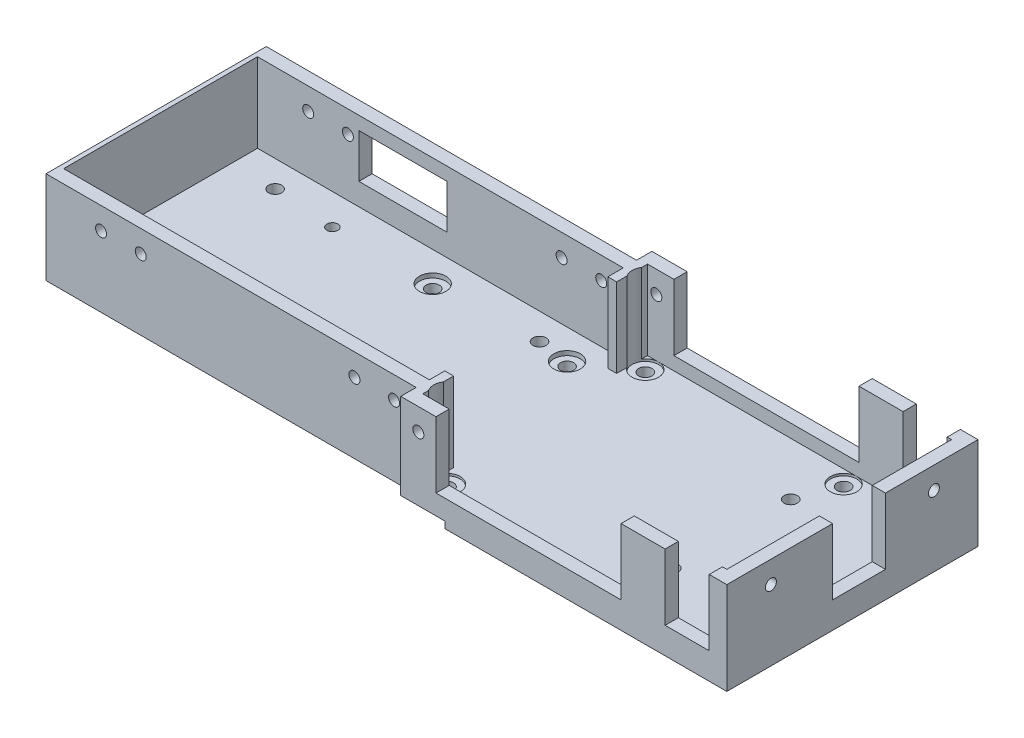
from build123d import *

# Parameters (mm, degrees)
SKETCH1_W               = 158
SKETCH1_H               = 50
BOSS_EXTRUDE1_DEPTH     = 3
SKETCH2_R               = 1.5
SKETCH2_R_2             = 1.25
CUT_EXTRUDE1_DEPTH      = 4
SKETCH4_W               = 74
SKETCH4_H               = 3.5
BOSS_EXTRUDE2_DEPTH     = 3
SKETCH5_R               = 1.5
CUT_EXTRUDE3_DEPTH      = 4
SKETCH6_W               = 84
SKETCH6_H               = 3
SKETCH6_W_2             = 8
SKETCH6_W_3             = 2
SKETCH6_H_2             = 7
SKETCH6_W_4             = 4
SKETCH6_W_5             = 3
SKETCH6_H_3             = 21
SKETCH6_H_4             = 18
SKETCH6_W_6             = 10
BOSS_EXTRUDE3_DEPTH     = 18
SKETCH8_W               = 10
SKETCH8_H               = 3
SKETCH8_H_2             = 2
SKETCH8_W_2             = 42
SKETCH8_W_3             = 3
SKETCH8_H_3             = 12
BOSS_EXTRUDE4_DEPTH     = 3
CUT_EXTRUDE4_REACH      = 55.5
SKETCH9_W               = 20
SKETCH9_H               = 10
CUT_EXTRUDE5_REACH      = 160
SKETCH10_R              = 1.25
SKETCH11_R              = 1.25
CUT_EXTRUDE6_DEPTH      = 54.5
SKETCH12_R              = 1.25
CUT_EXTRUDE7_DEPTH      = 58
SKETCH13_W              = 10
SKETCH13_H              = 1.5
CUT_EXTRUDE8_DEPTH      = 1.5
SKETCH14_R              = 3
CUT_EXTRUDE9_DEPTH      = 19
CUT_EXTRUDE9_DEPTH_BACK = 0.5
SKETCH15_R              = 3
CUT_EXTRUDE10_DEPTH     = 1
SKETCH17_W              = 1
SKETCH17_H              = 44
BOSS_EXTRUDE5_DEPTH     = 18


with BuildPart() as part:
    # Sketch1 → Boss-Extrude1 (new body)
    with BuildSketch(Plane(origin=(0, 0, 0), x_dir=(1, 0, 0), z_dir=(0, 1, 0))):
        with Locations((-43.62052506, -3.090692124)):
            Rectangle(SKETCH1_W, SKETCH1_H)
    extrude(amount=BOSS_EXTRUDE1_DEPTH)

    # Sketch2 → Cut-Extrude1 (cut, through all)
    with BuildSketch(Plane(origin=(0, 3, 0), x_dir=(1, 0, 0), z_dir=(0, 1, 0))):
        with Locations((-75.12052506, 12.159307876)):
            Circle(SKETCH2_R)
        with Locations((-75.12052506, -18.340692124)):
            Circle(SKETCH2_R)
        with Locations((-44.62052506, -18.340692124)):
            Circle(SKETCH2_R)
        with Locations((-44.62052506, 12.159307876)):
            Circle(SKETCH2_R)
        with Locations((7.87947494, -16.590692124)):
            Circle(SKETCH2_R)
        with Locations((7.87947494, 10.409307876)):
            Circle(SKETCH2_R)
        with Locations((-111.62052506, -19.090692124)):
            Circle(SKETCH2_R)
        with Locations((-111.62052506, 12.909307876)):
            Circle(SKETCH2_R)
        with Locations((-97.62052506, 11.909307876)):
            Circle(SKETCH2_R_2)
        with Locations((-97.62052506, -18.090692124)):
            Circle(SKETCH2_R_2)
        with Locations((-51.62052506, 12.909307876)):
            Circle(SKETCH2_R)
        with Locations((-51.62052506, -19.090692124)):
            Circle(SKETCH2_R)
    extrude(amount=-CUT_EXTRUDE1_DEPTH, mode=Mode.SUBTRACT)

    # Sketch4 → Boss-Extrude2 (add)
    with BuildSketch(Plane(origin=(0, 3, 0), x_dir=(1, 0, 0), z_dir=(0, 1, 0))):
        with Locations((-1.62052506, -29.840692124)):
            Rectangle(SKETCH4_W, SKETCH4_H)
        with Locations((-1.62052506, 23.659307876)):
            Rectangle(SKETCH4_W, SKETCH4_H)
    extrude(amount=-BOSS_EXTRUDE2_DEPTH)

    # Sketch5 → Cut-Extrude3 (cut, through all)
    with BuildSketch(Plane(origin=(0, 3, 0), x_dir=(1, 0, 0), z_dir=(0, 1, 0))):
        with Locations((-34.12052506, 19.409307876)):
            Circle(SKETCH5_R)
        with Locations((-34.12052506, -25.590692124)):
            Circle(SKETCH5_R)
        with Locations((10.87947494, 19.409307876)):
            Circle(SKETCH5_R)
        with Locations((10.87947494, -25.590692124)):
            Circle(SKETCH5_R)
    extrude(amount=-CUT_EXTRUDE3_DEPTH, mode=Mode.SUBTRACT)

    # Sketch6 → Boss-Extrude3 (add)
    with BuildSketch(Plane(origin=(0, 3, 0), x_dir=(1, 0, 0), z_dir=(0, 1, 0))):
        Polygon((35.37947494, 25.409307876), (31.37947494, 25.409307876), (31.37947494, 22.409307876), (32.37947494, 22.409307876), (35.37947494, 22.409307876), align=None)
        with Locations((-80.62052506, -26.590692124)):
            Rectangle(SKETCH6_W, SKETCH6_H)
        with Locations((-80.62052506, 20.409307876)):
            Rectangle(SKETCH6_W, SKETCH6_H)
        with Locations((-34.62052506, 23.909307876)):
            Rectangle(SKETCH6_W_2, SKETCH6_H)
        with Locations((-34.62052506, -30.090692124)):
            Rectangle(SKETCH6_W_2, SKETCH6_H)
        with Locations((-37.62052506, -25.090692124)):
            Rectangle(SKETCH6_W_3, SKETCH6_H_2)
        with Locations((-37.62052506, 18.909307876)):
            Rectangle(SKETCH6_W_3, SKETCH6_H_2)
        with Locations((33.37947494, -30.090692124)):
            Rectangle(SKETCH6_W_4, SKETCH6_H)
        with Locations((33.87947494, -18.090692124)):
            Rectangle(SKETCH6_W_5, SKETCH6_H_3)
        with Locations((33.87947494, 13.409307876)):
            Rectangle(SKETCH6_W_5, SKETCH6_H_4)
        with Locations((16.37947494, -30.090692124)):
            Rectangle(SKETCH6_W_6, SKETCH6_H)
        with Locations((16.37947494, 23.909307876)):
            Rectangle(SKETCH6_W_6, SKETCH6_H)
    extrude(amount=BOSS_EXTRUDE3_DEPTH)

    # Sketch8 → Boss-Extrude4 (add)
    with BuildSketch(Plane(origin=(0, 3, 0), x_dir=(1, 0, 0), z_dir=(0, 1, 0))):
        with Locations((26.37947494, -30.090692124)):
            Rectangle(SKETCH8_W, SKETCH8_H)
        with Locations((26.37947494, 24.409307876)):
            Rectangle(SKETCH8_W, SKETCH8_H_2)
        with Locations((-9.62052506, 23.909307876)):
            Rectangle(SKETCH8_W_2, SKETCH8_H)
        with Locations((-9.62052506, -30.090692124)):
            Rectangle(SKETCH8_W_2, SKETCH8_H)
        with Locations((33.87947494, -1.590692124)):
            Rectangle(SKETCH8_W_3, SKETCH8_H_3)
    extrude(amount=BOSS_EXTRUDE4_DEPTH)

    # Sketch9 → Cut-Extrude4 (cut, up to next)
    with BuildSketch(Plane(origin=(0, 0, -21.909307876), x_dir=(-1, 0, 0), z_dir=(0, 0, -1)), mode=Mode.PRIVATE) as cut_extrude4_sk1:
        with Locations((88.62052506, 13)):
            Rectangle(SKETCH9_W, SKETCH9_H)
    cut_extrude4_tool1 = extrude(cut_extrude4_sk1.sketch, amount=-CUT_EXTRUDE4_REACH, mode=Mode.PRIVATE) & part.part
    add(cut_extrude4_tool1.solids().sort_by_distance((-88.620525, 13, -21.909308))[0], mode=Mode.SUBTRACT)

    # Sketch10 → Cut-Extrude5 (cut, up to next)
    with BuildSketch(Plane(origin=(35.37947494, 0, 0), x_dir=(0, 0, -1), z_dir=(1, 0, 0)), mode=Mode.PRIVATE) as cut_extrude5_sk1:
        with Locations((-21.590692124, 16)):
            Circle(SKETCH10_R)
    cut_extrude5_tool1 = extrude(cut_extrude5_sk1.sketch, amount=-CUT_EXTRUDE5_REACH, mode=Mode.PRIVATE) & part.part
    add(cut_extrude5_tool1.solids().sort_by_distance((35.379475, 16, 21.590692))[0], mode=Mode.SUBTRACT)
    # Sketch10 → Cut-Extrude5 (cut, up to next)
    with BuildSketch(Plane(origin=(35.37947494, 0, 0), x_dir=(0, 0, -1), z_dir=(1, 0, 0)), mode=Mode.PRIVATE) as cut_extrude5_sk2:
        with Locations((15.409307876, 16)):
            Circle(SKETCH10_R)
    cut_extrude5_tool2 = extrude(cut_extrude5_sk2.sketch, amount=-CUT_EXTRUDE5_REACH, mode=Mode.PRIVATE) & part.part
    add(cut_extrude5_tool2.solids().sort_by_distance((35.379475, 16, -15.409308))[0], mode=Mode.SUBTRACT)

    # Sketch11 → Cut-Extrude6 (cut, through all)
    with BuildSketch(Plane(origin=(0, 0, -21.909307876), x_dir=(-1, 0, 0), z_dir=(0, 0, -1))):
        with Locations((43.62052506, 16)):
            Circle(SKETCH11_R)
        with Locations((110.12052506, 16)):
            Circle(SKETCH11_R)
        with Locations((52.62052506, 16)):
            Circle(SKETCH11_R)
        with Locations((101.12052506, 16)):
            Circle(SKETCH11_R)
    extrude(amount=-CUT_EXTRUDE6_DEPTH, mode=Mode.SUBTRACT)

    # Sketch12 → Cut-Extrude7 (cut, through all)
    with BuildSketch(Plane(origin=(0, 0, -25.409307876), x_dir=(-1, 0, 0), z_dir=(0, 0, -1))):
        with Locations((34.62052506, 16)):
            Circle(SKETCH12_R)
    extrude(amount=-CUT_EXTRUDE7_DEPTH, mode=Mode.SUBTRACT)

    # Sketch13 → Cut-Extrude8 (cut)
    with BuildSketch(Plane(origin=(0, 0, 0), x_dir=(-1, 0, 0), z_dir=(0, -1, 0))):
        with Locations((33.62052506, -30.840692124)):
            Rectangle(SKETCH13_W, SKETCH13_H)
        with Locations((33.62052506, 24.659307876)):
            Rectangle(SKETCH13_W, SKETCH13_H)
    extrude(amount=-CUT_EXTRUDE8_DEPTH, mode=Mode.SUBTRACT)

    # Sketch14 → Cut-Extrude9 (cut, two sides)
    with BuildSketch(Plane(origin=(0, 3, 0), x_dir=(1, 0, 0), z_dir=(0, 1, 0))) as cut_extrude9_sk:
        with Locations((10.87947494, -25.590692124)):
            Circle(SKETCH14_R)
        with Locations((-34.12052506, -25.590692124)):
            Circle(SKETCH14_R)
        with Locations((-34.12052506, 19.409307876)):
            Circle(SKETCH14_R)
        with Locations((10.87947494, 19.409307876)):
            Circle(SKETCH14_R)
    extrude(amount=CUT_EXTRUDE9_DEPTH, mode=Mode.SUBTRACT)
    extrude(cut_extrude9_sk.sketch, amount=-CUT_EXTRUDE9_DEPTH_BACK, mode=Mode.SUBTRACT)

    # Sketch15 → Cut-Extrude10 (cut)
    with BuildSketch(Plane(origin=(0, 3, 0), x_dir=(1, 0, 0), z_dir=(0, 1, 0))):
        with Locations((-75.12052506, 12.159307876)):
            Circle(SKETCH15_R)
        with Locations((-75.12052506, -18.340692124)):
            Circle(SKETCH15_R)
        with Locations((-44.62052506, 12.159307876)):
            Circle(SKETCH15_R)
        with Locations((-44.62052506, -18.340692124)):
            Circle(SKETCH15_R)
    extrude(amount=-CUT_EXTRUDE10_DEPTH, mode=Mode.SUBTRACT)

    # Sketch17 → Boss-Extrude5 (add)
    with BuildSketch(Plane(origin=(0, 3, 0), x_dir=(1, 0, 0), z_dir=(0, 1, 0))):
        with Locations((-122.12052506, -3.090692124)):
            Rectangle(SKETCH17_W, SKETCH17_H)
    extrude(amount=BOSS_EXTRUDE5_DEPTH)


solid = part.part
